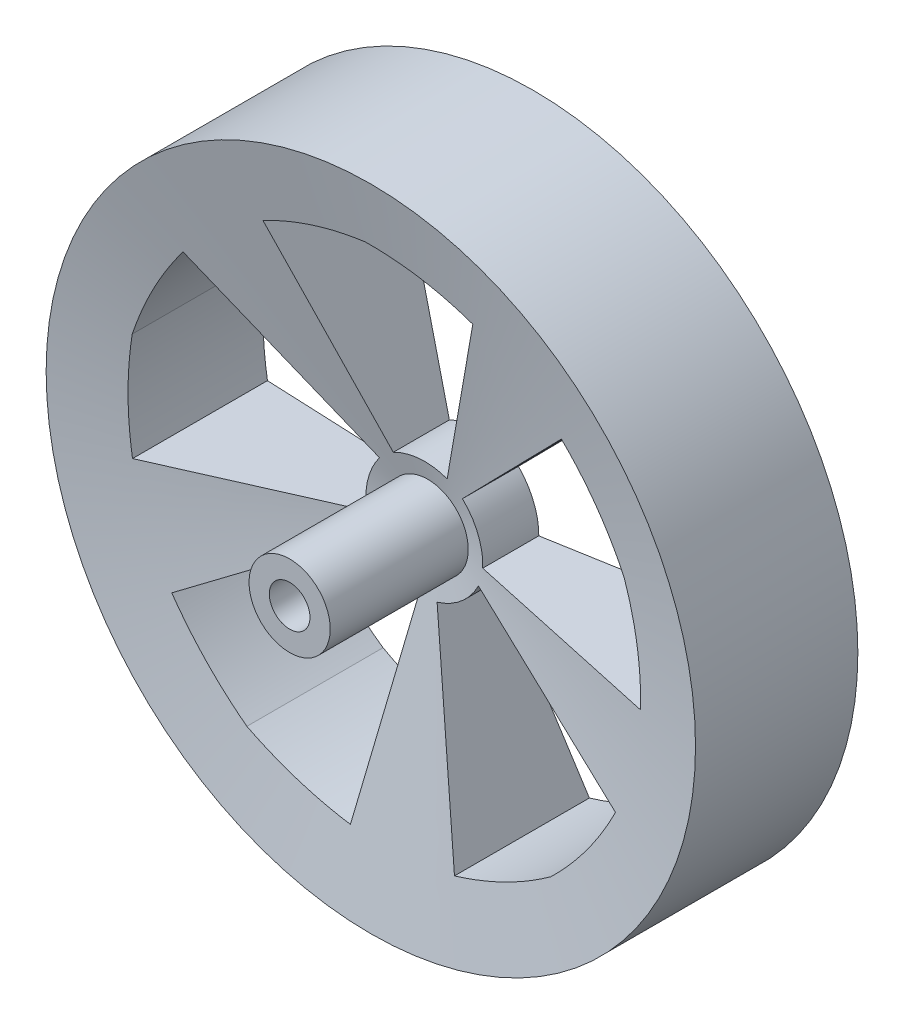
from build123d import *

# Parameters (mm, degrees)
CUT_EXTRUDE1_DEPTH       = 11
SKETCH4_R                = 2.5
BOSS_EXTRUDE1_DEPTH      = 5
BOSS_EXTRUDE1_DEPTH_BACK = 5
SKETCH5_R                = 1.25
CUT_EXTRUDE2_DEPTH       = 5


with BuildPart() as part:
    # Sketch2 → Revolve2 (revolve)
    with BuildSketch(Plane(origin=(0, 0, 0), x_dir=(0, 0, -1), z_dir=(1, 0, 0))):
        Polygon((-0.947368421, 0), (3.052631579, 20), (-6.947368421, 20), (-2.947368421, 0), align=None)
    revolve(axis=Axis((0, 0, 1.947368421), (0, 0, -1)))

    # Sketch3 → Cut-Extrude1 (cut, through all)
    with BuildSketch(Plane.XY.offset(6.947368421)):
        with BuildLine():
            Line((1.427639009, 3.341779315), (5.437421768, 14.812857935))
            ThreePointArc((5.437421768, 14.812857935), (2.195765142, 15.648221894), (-1.139973889, 15.929319272))
            ThreePointArc((-1.139973889, 15.929319272), (-4.401690999, 15.176078194), (-7.49135707, 13.887616244))
            Line((-7.49135707, 13.887616244), (-1.888958706, 3.104428633))
            ThreePointArc((-1.888958706, 3.104428633), (-0.255193929, 3.565928667), (1.427639009, 3.341779315))
        make_face()
        with BuildLine():
            Line((3.619385709, -0.325098782), (15.768120796, -0.593870567))
            ThreePointArc((15.768120796, -0.593870567), (15.560872146, 2.74726975), (14.797411589, 6.00660996))
            ThreePointArc((14.797411589, 6.00660996), (13.073110736, 8.875922977), (10.892951279, 11.416213388))
            Line((10.892951279, 11.416213388), (2.368766739, 2.755827692))
            ThreePointArc((2.368766739, 2.755827692), (3.312540434, 1.344636408), (3.619385709, -0.325098782))
        make_face()
        with BuildLine():
            Line((0.809264378, -3.542701412), (4.307812822, -15.17989013))
            ThreePointArc((4.307812822, -15.17989013), (7.421382738, -13.950315812), (10.285277197, -12.217030159))
            ThreePointArc((10.285277197, -12.217030159), (12.481317772, -9.690456113), (14.223571198, -6.832008347))
            Line((14.223571198, -6.832008347), (3.352937062, -1.401233452))
            ThreePointArc((3.352937062, -1.401233452), (2.302456507, -2.734897664), (0.809264378, -3.542701412))
        make_face()
        with BuildLine():
            Line((-3.119232818, -1.864411103), (-13.105746054, -8.787817479))
            ThreePointArc((-13.105746054, -8.787817479), (-10.97420537, -11.369039076), (-8.440760697, -13.55714984))
            ThreePointArc((-8.440760697, -13.55714984), (-5.359232128, -14.864954222), (-2.102300837, -15.638626758))
            Line((-2.102300837, -15.638626758), (-0.296537672, -3.621837592))
            ThreePointArc((-0.296537672, -3.621837592), (-1.889544056, -3.03489612), (-3.119232818, -1.864411103))
        make_face()
        with BuildLine():
            Line((-2.737056278, 2.390431982), (-12.407609332, 9.748720242))
            ThreePointArc((-12.407609332, 9.748720242), (-14.203814656, 6.923863244), (-15.501954199, 3.838250768))
            ThreePointArc((-15.501954199, 3.838250768), (-15.793505381, 0.503409163), (-15.52286457, -2.833194526))
            Line((-15.52286457, -2.833194526), (-3.536207423, -0.837185281))
            ThreePointArc((-3.536207423, -0.837185281), (-3.470258956, 0.85922871), (-2.737056278, 2.390431982))
        make_face()
    extrude(amount=-CUT_EXTRUDE1_DEPTH, mode=Mode.SUBTRACT)

    # Sketch4 → Boss-Extrude1 (add, two sides)
    with BuildSketch(Plane.XY.offset(6.947368421)) as boss_extrude1_sk:
        Circle(SKETCH4_R)
    extrude(amount=BOSS_EXTRUDE1_DEPTH)
    extrude(boss_extrude1_sk.sketch, amount=-BOSS_EXTRUDE1_DEPTH_BACK)

    # Sketch5 → Cut-Extrude2 (cut)
    with BuildSketch(Plane.XY.offset(11.947368421)):
        Circle(SKETCH5_R)
    extrude(amount=-CUT_EXTRUDE2_DEPTH, mode=Mode.SUBTRACT)


solid = part.part
